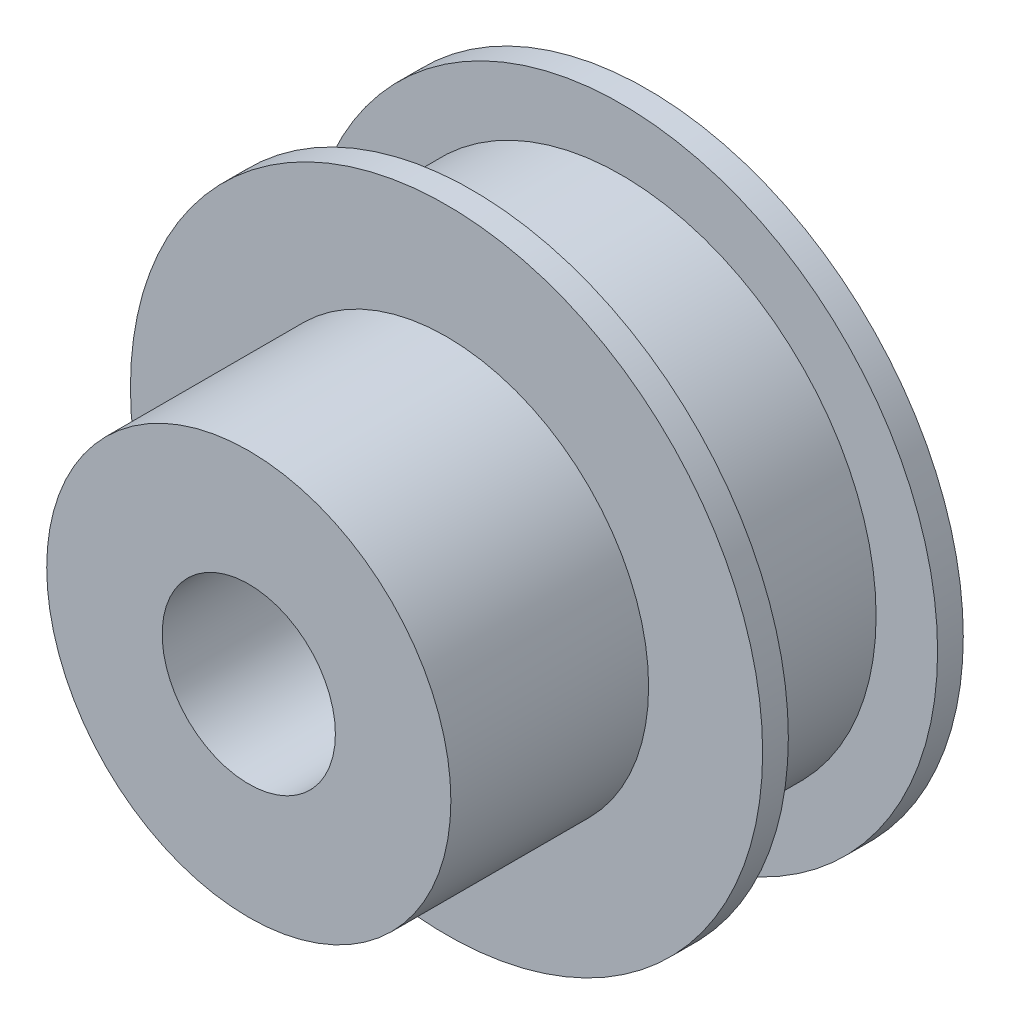
from build123d import *


with BuildPart() as part:
    # Sketch1 → Revolve1 (revolve)
    with BuildSketch(Plane(origin=(0, 0, 0), x_dir=(0, 0, -1), z_dir=(1, 0, 0))):
        Polygon((0, 3.81), (17.526, 3.81), (17.526, 13.9065), (16.3957, 13.9065), (16.3957, 11.2014), (9.8298, 11.2014), (9.8298, 13.9065), (8.6995, 13.9065), (8.6995, 8.89), (0, 8.89), align=None)
    revolve(axis=Axis((0, 0, 0), (0, 0, -1)))


solid = part.part
